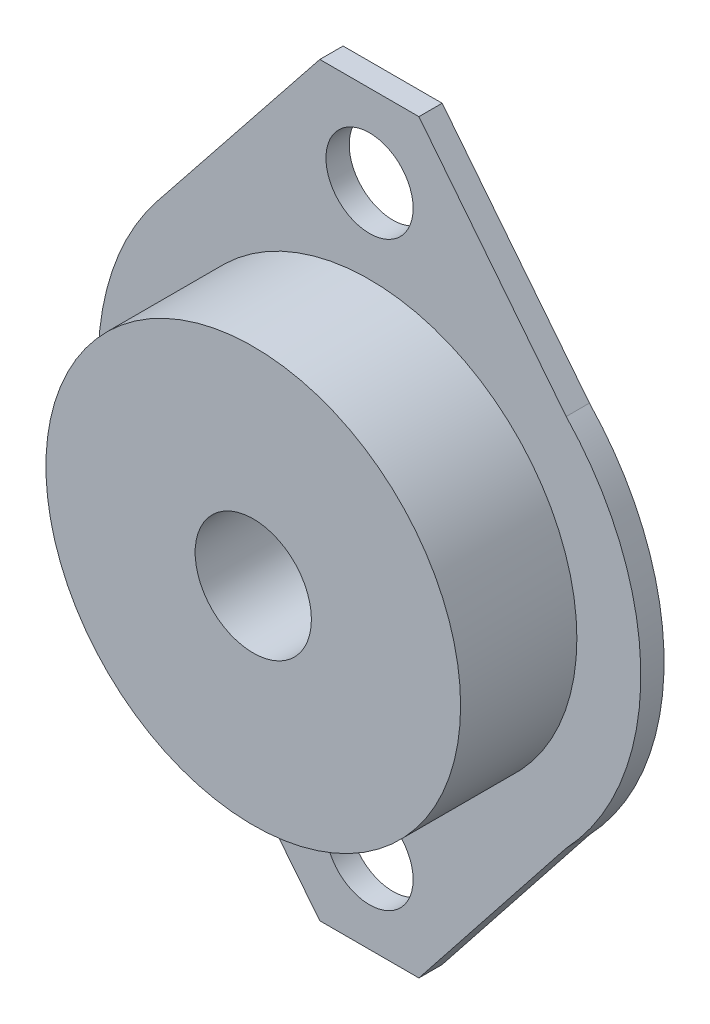
from build123d import *

# Parameters (mm, degrees)
SKETCH_1_R          = 2.25
SKETCH_1_R_2        = 3
EXTRUDE_1_DEPTH     = 1.2
SKETCH_2_R          = 10.7
SKETCH_2_R_2        = 3
EXTRUDE_2_DEPTH     = 6
CUT_EXTRUDE_1_DEPTH = 6


with BuildPart() as part:
    # ｽｹｯﾁ1 → ﾎﾞｽ - 押し出し1 (new body)
    with BuildSketch(Plane.XY):
        with BuildLine():
            Line((-10.949386038, 8.724158721), (0, 22.466349623))
            Line((0, 22.466349623), (10.148136548, 9.644445272))
            ThreePointArc((10.148136548, 9.644445272), (14, 0), (10.148136548, -9.644445272))
            Line((10.148136548, -9.644445272), (0, -22.466349623))
            Line((0, -22.466349623), (-10.949386038, -8.724158721))
            ThreePointArc((-10.949386038, -8.724158721), (-14, 0), (-10.949386038, 8.724158721))
        make_face()
        with Locations((0, 15)):
            Circle(SKETCH_1_R, mode=Mode.SUBTRACT)
        with Locations((0, -15)):
            Circle(SKETCH_1_R, mode=Mode.SUBTRACT)
        Circle(SKETCH_1_R_2, mode=Mode.SUBTRACT)
    extrude(amount=EXTRUDE_1_DEPTH)

    # ｽｹｯﾁ2 → ﾎﾞｽ - 押し出し2 (add)
    with BuildSketch(Plane.XY.offset(1.2)):
        Circle(SKETCH_2_R)
        Circle(SKETCH_2_R_2, mode=Mode.SUBTRACT)
    extrude(amount=EXTRUDE_2_DEPTH)

    # ｽｹｯﾁ3 → ｶｯﾄ - 押し出し1 (cut)
    with BuildSketch(Plane.XY.offset(1.2)):
        Polygon((-2.565036178, 19.24706256), (2.547965093, 19.24706256), (0, 22.466349623), align=None)
        Polygon((-2.565036178, -19.24706256), (2.547965093, -19.24706256), (0, -22.466349623), align=None)
    extrude(amount=-CUT_EXTRUDE_1_DEPTH, mode=Mode.SUBTRACT)


solid = part.part
